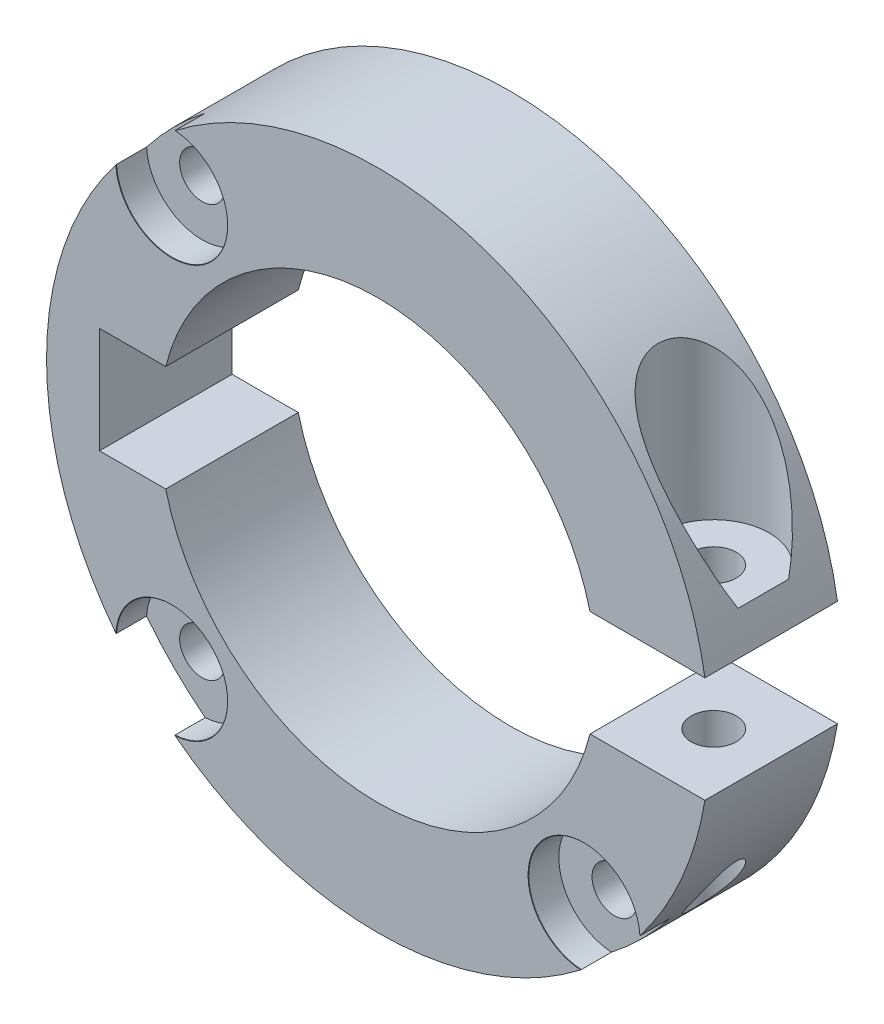
from build123d import *

# Parameters (mm, degrees)
BOSS_EXTRUDE1_DEPTH                           = 10
CBORE_FOR_M3_HEX_HEAD_MACHINE_SCREW3_AT_COUNT = 2
CBORE_FOR_M3_HEX_HEAD_MACHINE_SCREW3_AT_PITCH = 31.112698372
CBORE_FOR_M3_HEX_HEAD_MACHINE_SCREW3_2_COUNT  = 2
CBORE_FOR_M3_HEX_HEAD_MACHINE_SCREW3_2_PITCH  = 44


with BuildPart() as part:
    # Sketch1 → Boss-Extrude1 (new body)
    with BuildSketch(Plane.XY):
        with BuildLine():
            Line((-16.007810594, -4), (-21, -4))
            Line((-21, -4), (-21, 4))
            Line((-21, 4), (-16.007810594, 4))
            ThreePointArc((-16.007810594, 4), (0, 16.5), (16.007810594, 4))
            Line((16.007810594, 4), (24.677925359, 4))
            ThreePointArc((24.677925359, 4), (-25, 0), (24.677925359, -4))
            Line((24.677925359, -4), (16.007810594, -4))
            ThreePointArc((16.007810594, -4), (0, -16.5), (-16.007810594, -4))
        make_face()
    extrude(amount=BOSS_EXTRUDE1_DEPTH)

    # Sketch6 → CBORE for M3 Hex Head Machine Screw2 (revolve, cut)
    with BuildSketch(Plane(origin=(20.342867976, 24, 5), x_dir=(0, 0, 1), z_dir=(1, 0, 0))):
        Polygon((0, 0), (0, 49), (1.7, 49), (1.7, 17.3), (4.2, 17.3), (4.2, 0.025), (4.225, 0), align=None)
    revolve(axis=Axis((20.342867976, 30.35, 5), (0, -1, 0)), mode=Mode.SUBTRACT)

    # Sketch8 → CBORE for M3 Hex Head Machine Screw3 (revolve, cut)
    with BuildSketch(Plane(origin=(-15.556349186, 15.556349186, 10), x_dir=(0, -1, 0), z_dir=(1, 0, 0))):
        Polygon((0, 0), (0, 10), (1.7, 10), (1.7, 2.3), (4.2, 2.3), (4.2, 0.025), (4.225, 0), align=None)
    cbore_for_m3_hex_head_machine_screw3 = revolve(axis=Axis((-15.556349186, 15.556349186, 16.35), (0, 0, -1)), mode=Mode.SUBTRACT)

    # CBORE for M3 Hex Head Machine Screw3 at: CBORE for M3 Hex Head Machine Screw3 ×2
    with Locations(*[(0, -i * CBORE_FOR_M3_HEX_HEAD_MACHINE_SCREW3_AT_PITCH, 0) for i in range(1, CBORE_FOR_M3_HEX_HEAD_MACHINE_SCREW3_AT_COUNT)]):
        add(cbore_for_m3_hex_head_machine_screw3, mode=Mode.SUBTRACT)

    # CBORE for M3 Hex Head Machine Screw3 2: CBORE for M3 Hex Head Machine Screw3 ×2
    with Locations(*[Vector(0.707106781, -0.707106781, 0) * (i * CBORE_FOR_M3_HEX_HEAD_MACHINE_SCREW3_2_PITCH) for i in range(1, CBORE_FOR_M3_HEX_HEAD_MACHINE_SCREW3_2_COUNT)]):
        add(cbore_for_m3_hex_head_machine_screw3, mode=Mode.SUBTRACT)


solid = part.part
